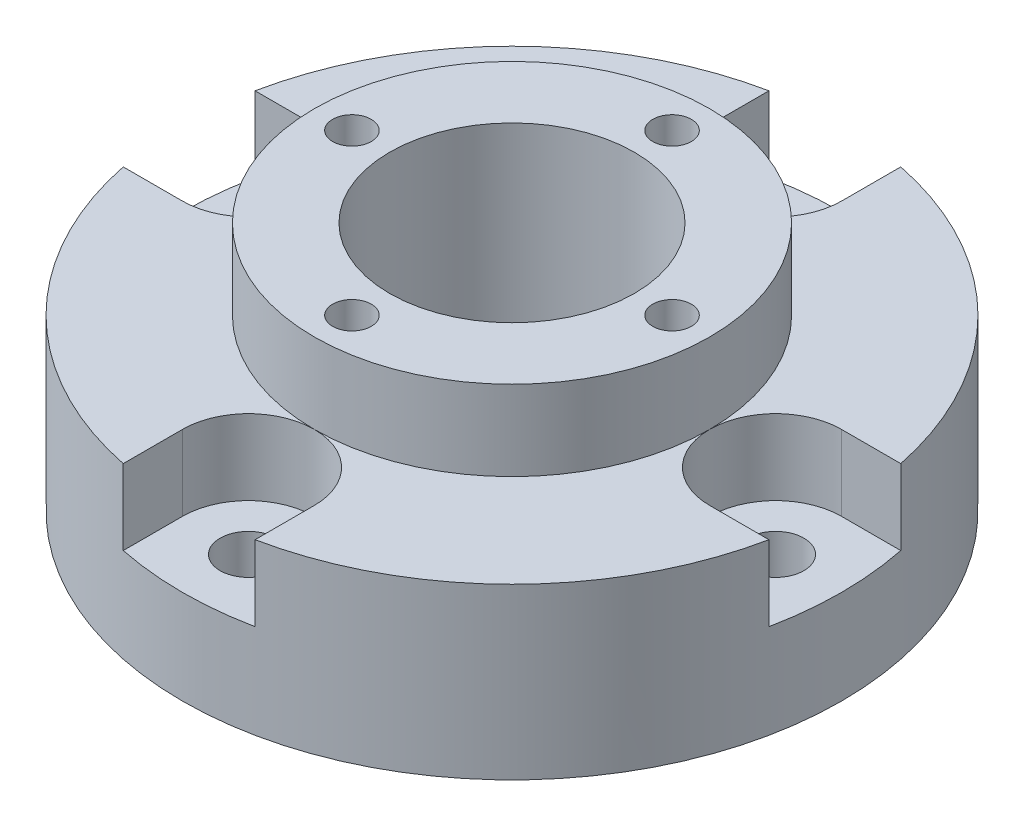
from build123d import *

# Parameters (mm, degrees)
HOLE_WIZARD_4_1_4_1_1_D     = 4.1
HOLE_WIZARD_4_1_4_1_1_DEPTH = 26.501
HOLE_WIZARD_6_0_6_1_D       = 6
HOLE_WIZARD_6_0_6_1_DEPTH   = 18.001
CUT_EXTRUDE_1_DEPTH         = 8
PATTERN_CIRCULAR_1_COUNT    = 4


with BuildPart() as part:
    # Эскиз1 → Повернуть1 (revolve)
    with BuildSketch(Plane.XY):
        Polygon((-13, 0), (-13, 26.5), (-21, 26.5), (-21, 18), (-35, 18), (-35, 0), align=None)
    revolve(axis=Axis((0, 0, 0), (0, 1, 0)))

    # Диаметр отверстия Ø4.1 (4.1)1
    with Locations(Plane(origin=(0, 26.5, 0), x_dir=(1, 0, 0), z_dir=(0, 1, 0))):
        with Locations((17, 0)):
            hole_wizard_4_1_4_1_1 = Hole(HOLE_WIZARD_4_1_4_1_1_D / 2, depth=HOLE_WIZARD_4_1_4_1_1_DEPTH)

    # Диаметр отверстия Ø6.0 (6)1
    with Locations(Plane(origin=(0, 18, 0), x_dir=(1, 0, 0), z_dir=(0, 1, 0))):
        with Locations((28, 0)):
            hole_wizard_6_0_6_1 = Hole(HOLE_WIZARD_6_0_6_1_D / 2, depth=HOLE_WIZARD_6_0_6_1_DEPTH)

    # Эскиз4 → Вырез-Вытянуть1 (cut)
    with BuildSketch(Plane(origin=(0, 18, 0), x_dir=(1, 0, 0), z_dir=(0, 1, 0))):
        with BuildLine():
            Line((28, 7), (48, 7))
            Line((48, 7), (48, -7))
            Line((48, -7), (28, -7))
            ThreePointArc((28, -7), (21, 0), (28, 7))
        make_face()
    cut_extrude_1 = extrude(amount=-CUT_EXTRUDE_1_DEPTH, mode=Mode.SUBTRACT)

    # Круговой массив1: Диаметр отверстия Ø4.1 (4.1)1, Диаметр отверстия Ø6.0 (6)1, Вырез-Вытянуть1 ×4 about axis
    pattern_circular_1_axis = Axis((0, 0, 0), (0, 1, 0))
    for i in range(1, PATTERN_CIRCULAR_1_COUNT):
        add(hole_wizard_4_1_4_1_1.rotate(pattern_circular_1_axis, i * 360 / PATTERN_CIRCULAR_1_COUNT), mode=Mode.SUBTRACT)
        add(hole_wizard_6_0_6_1.rotate(pattern_circular_1_axis, i * 360 / PATTERN_CIRCULAR_1_COUNT), mode=Mode.SUBTRACT)
        add(cut_extrude_1.rotate(pattern_circular_1_axis, i * 360 / PATTERN_CIRCULAR_1_COUNT), mode=Mode.SUBTRACT)


solid = part.part
